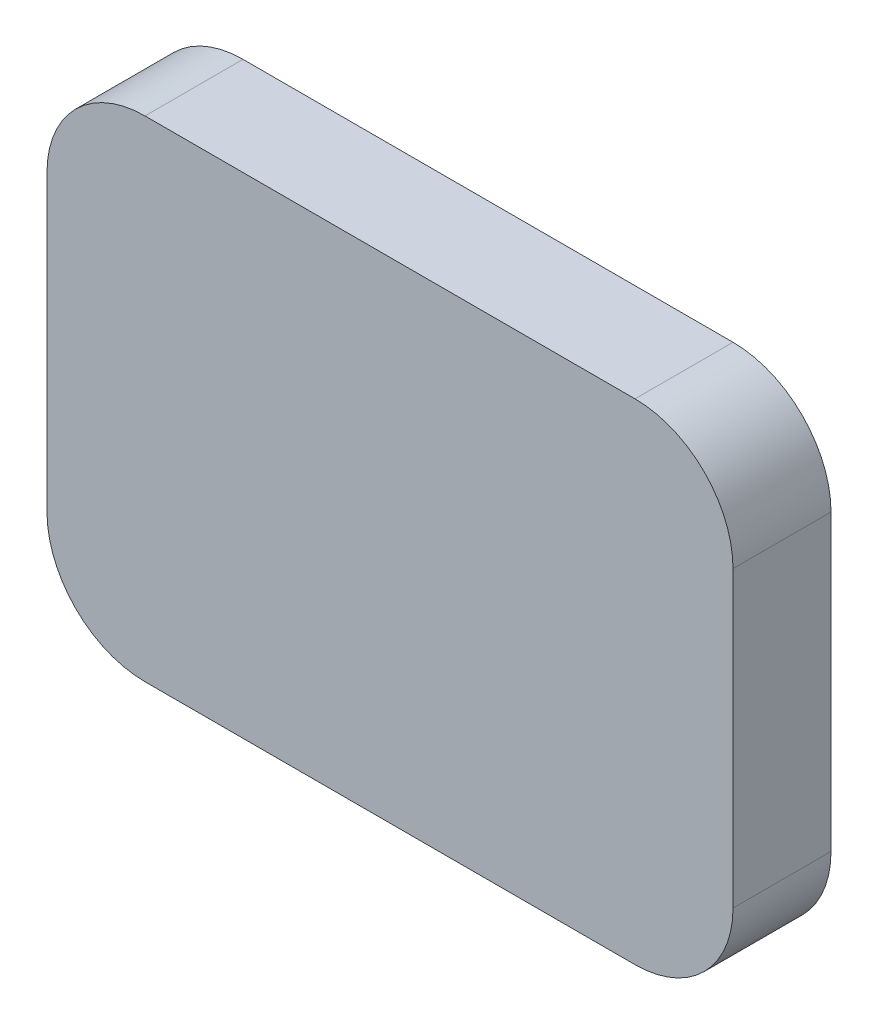
from build123d import *

# Parameters (mm, degrees)
SKETCH_1_W      = 70
SKETCH_1_H      = 50
EXTRUDE_1_DEPTH = 10
FILLET_1_R      = 10


with BuildPart() as part:
    # 스케치1 → 보스-돌출1 (new body)
    with BuildSketch(Plane.XY):
        with Locations((35, -25)):
            Rectangle(SKETCH_1_W, SKETCH_1_H)
    extrude(amount=EXTRUDE_1_DEPTH)

    # 필렛1
    fillet_1_edges = [part.edges().sort_by_distance(p)[0] for p in [
        (0, 0, 5),
        (70, 0, 5),
        (70, -50, 5),
        (0, -50, 5),
    ]]
    fillet(fillet_1_edges, radius=FILLET_1_R)


solid = part.part
